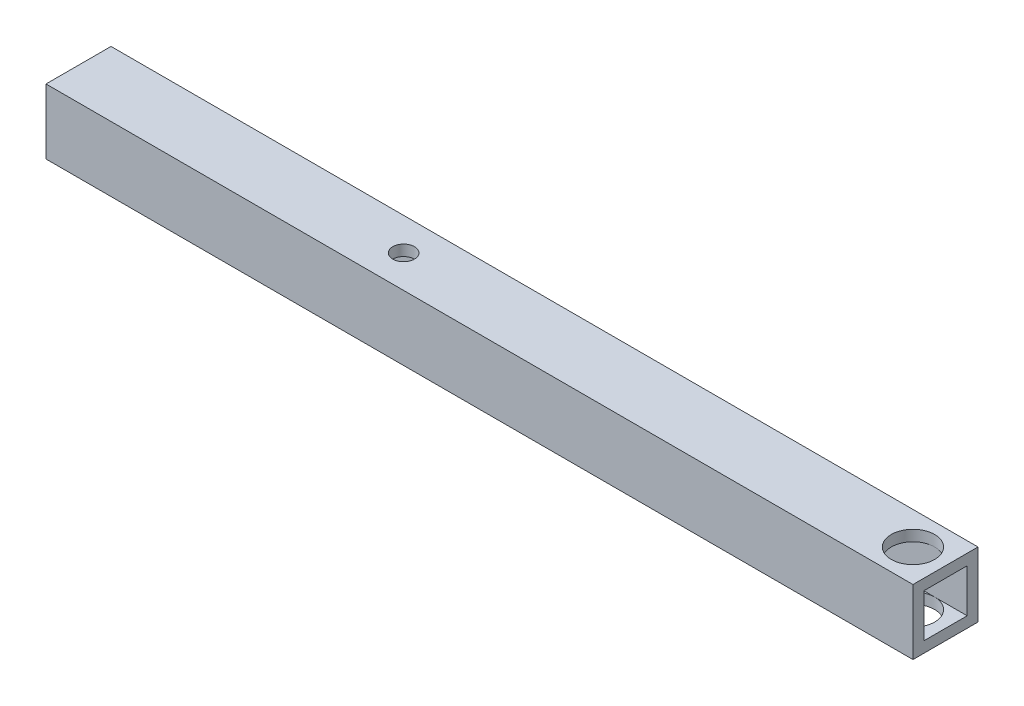
from build123d import *

# Parameters (mm, degrees)
SKETCH1_W           = 15
SKETCH1_H           = 15
SKETCH1_W_2         = 10
SKETCH1_H_2         = 10
BOSS_EXTRUDE1_DEPTH = 200
SKETCH2_R           = 5
CUT_EXTRUDE1_DEPTH  = 16
SKETCH3_R           = 2.5
CUT_EXTRUDE2_DEPTH  = 100


with BuildPart() as part:
    # Sketch1 → Boss-Extrude1 (new body)
    with BuildSketch(Plane(origin=(0, 0, 0), x_dir=(0, 0, -1), z_dir=(1, 0, 0))):
        Rectangle(SKETCH1_W, SKETCH1_H)
        Rectangle(SKETCH1_W_2, SKETCH1_H_2, mode=Mode.SUBTRACT)
    extrude(amount=BOSS_EXTRUDE1_DEPTH)

    # Sketch2 → Cut-Extrude1 (cut, through all)
    with BuildSketch(Plane(origin=(0, 7.5, 0), x_dir=(1, 0, 0), z_dir=(0, 1, 0))):
        with Locations((192.5, 0)):
            Circle(SKETCH2_R)
    extrude(amount=-CUT_EXTRUDE1_DEPTH, mode=Mode.SUBTRACT)

    # Sketch3 → Cut-Extrude2 (cut)
    with BuildSketch(Plane(origin=(0, 7.5, 0), x_dir=(1, 0, 0), z_dir=(0, 1, 0))):
        with Locations((75, 0)):
            Circle(SKETCH3_R)
    extrude(amount=-CUT_EXTRUDE2_DEPTH, mode=Mode.SUBTRACT)


solid = part.part
